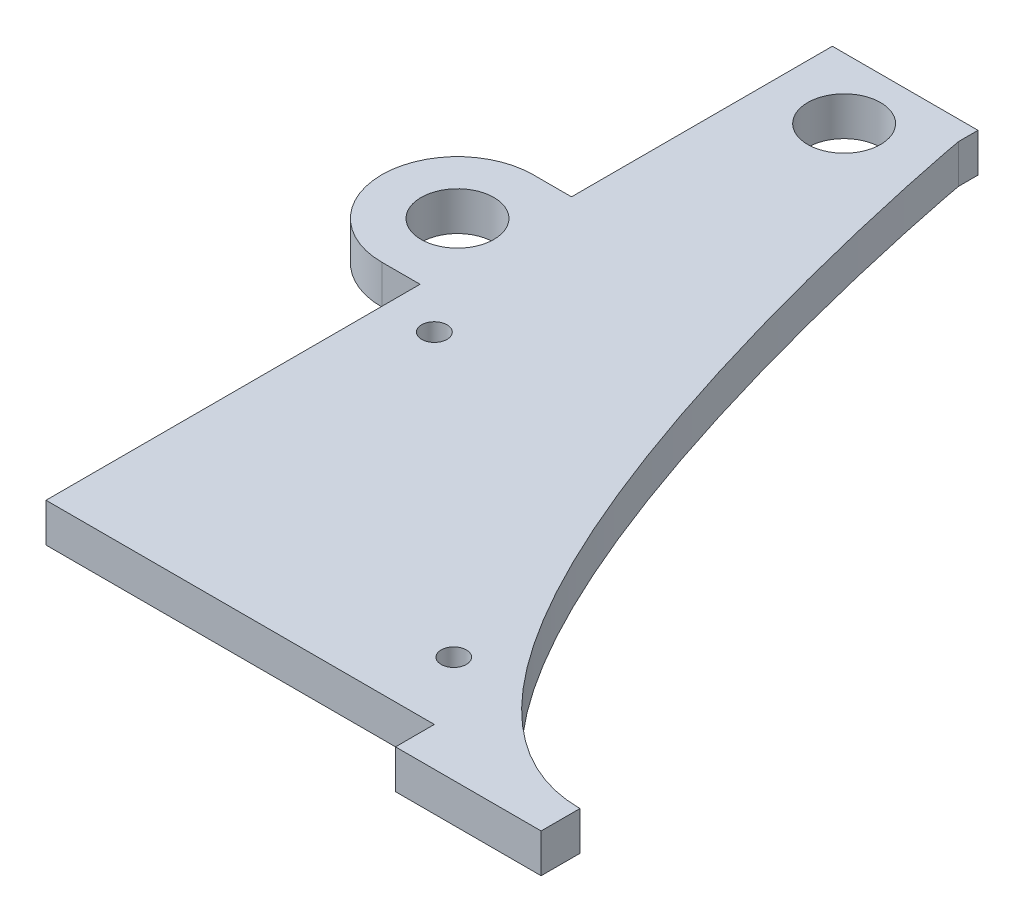
from build123d import *

# Parameters (mm, degrees)
SKETCH1_R               = 4.7625
BOSS_EXTRUDE1_DEPTH     = 5.08
SKETCH4_W               = 19.05
SKETCH4_H               = 5.08
BOSS_EXTRUDE2_DEPTH     = 5.08
SKETCH5_R               = 1.651
SKETCH5_R_2             = 1.660728382
CUT_EXTRUDE1_DEPTH      = 1.0000001
CUT_EXTRUDE1_DEPTH_BACK = 6.0800001
SKETCH6_R               = 4.7625
BOSS_EXTRUDE3_DEPTH     = 5.08


with BuildPart() as part:
    # Sketch1 → Boss-Extrude1 (new body)
    with BuildSketch(Plane(origin=(0, 0, 0), x_dir=(1, 0, 0), z_dir=(0, 1, 0))):
        with BuildLine():
            Line((-9.525, 53.975), (9.525, 53.975))
            Line((9.525, 53.975), (9.525, 51.435))
            add(Edge.make_bspline(
                [(9.525, 51.435), (9.525, 51.21454564), (27.819109584, -48.895), (60.325, -48.895)],
                knots=[0, 0, 0, 0, 1, 1, 1, 1], degree=3))
            Line((60.325, -48.895), (-9.525, -48.895))
            Line((-9.525, -48.895), (-9.525, 53.975))
        make_face()
        with Locations((0, 45.9867)):
            Circle(SKETCH1_R, mode=Mode.SUBTRACT)
    extrude(amount=BOSS_EXTRUDE1_DEPTH)

    # Sketch4 → Boss-Extrude2 (add)
    with BuildSketch(Plane(origin=(0, 5.08, 0), x_dir=(1, 0, 0), z_dir=(0, 1, 0))):
        with Locations((50.8, -51.435)):
            Rectangle(SKETCH4_W, SKETCH4_H)
    extrude(amount=-BOSS_EXTRUDE2_DEPTH)

    # Sketch5 → Cut-Extrude1 (cut, two sides)
    with BuildSketch(Plane.XZ) as cut_extrude1_sk:
        with Locations((34.925, 40.005)):
            Circle(SKETCH5_R)
        with Locations((-3.175, 4.445)):
            Circle(SKETCH5_R_2)
    extrude(amount=CUT_EXTRUDE1_DEPTH, mode=Mode.SUBTRACT)
    extrude(cut_extrude1_sk.sketch, amount=-CUT_EXTRUDE1_DEPTH_BACK, mode=Mode.SUBTRACT)

    # Sketch6 → Boss-Extrude3 (add)
    with BuildSketch(Plane.XZ):
        with BuildLine():
            Line((-14.535912, -0.037592), (-9.525, -0.037592))
            Line((-9.525, -0.037592), (-9.525, -1.398441508))
            ThreePointArc((-9.525, -1.398441508), (-4.629912, -9.943592), (-9.525, -18.488742492))
            Line((-9.525, -18.488742492), (-9.525, -19.849592))
            Line((-9.525, -19.849592), (-14.535912, -19.849592))
            ThreePointArc((-14.535912, -19.849592), (-24.441912, -9.943592), (-14.535912, -0.037592))
        make_face()
        with Locations((-14.535912, -9.943592)):
            Circle(SKETCH6_R, mode=Mode.SUBTRACT)
    extrude(amount=-BOSS_EXTRUDE3_DEPTH)


solid = part.part
